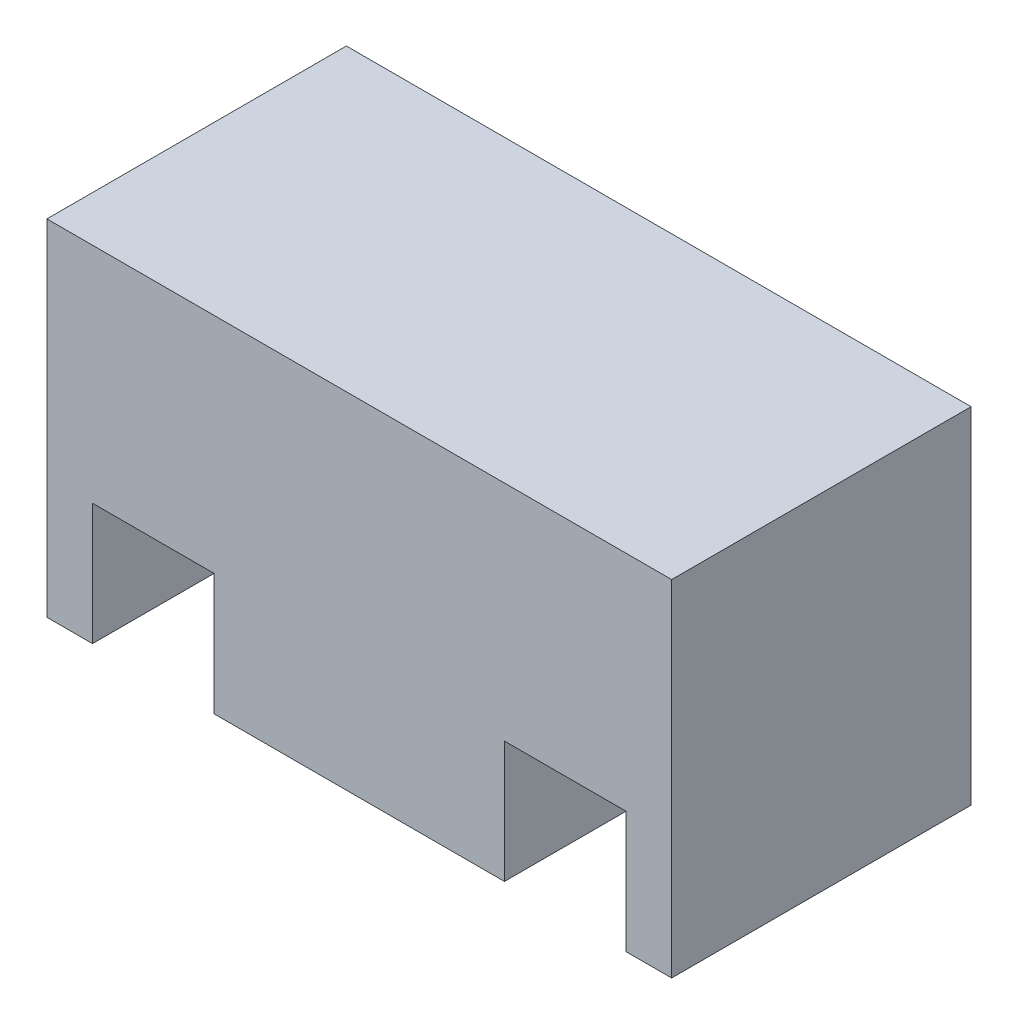
from build123d import *

# Parameters (mm, degrees)
SKETCH1_W           = 41.1
SKETCH1_H           = 22.7
BOSS_EXTRUDE1_DEPTH = 19.7
SKETCH2_W           = 8
SKETCH2_H           = 8
CUT_EXTRUDE1_DEPTH  = 20.7


with BuildPart() as part:
    # Sketch1 → Boss-Extrude1 (new body)
    with BuildSketch(Plane.XY):
        with Locations((0.13354401, 1.865189737)):
            Rectangle(SKETCH1_W, SKETCH1_H)
    extrude(amount=BOSS_EXTRUDE1_DEPTH)

    # Sketch2 → Cut-Extrude1 (cut, through all)
    with BuildSketch(Plane.XY.offset(19.7)):
        with Locations((-13.41645599, -5.484810263)):
            Rectangle(SKETCH2_W, SKETCH2_H)
        with Locations((13.68354401, -5.484810263)):
            Rectangle(SKETCH2_W, SKETCH2_H)
    extrude(amount=-CUT_EXTRUDE1_DEPTH, mode=Mode.SUBTRACT)


solid = part.part
